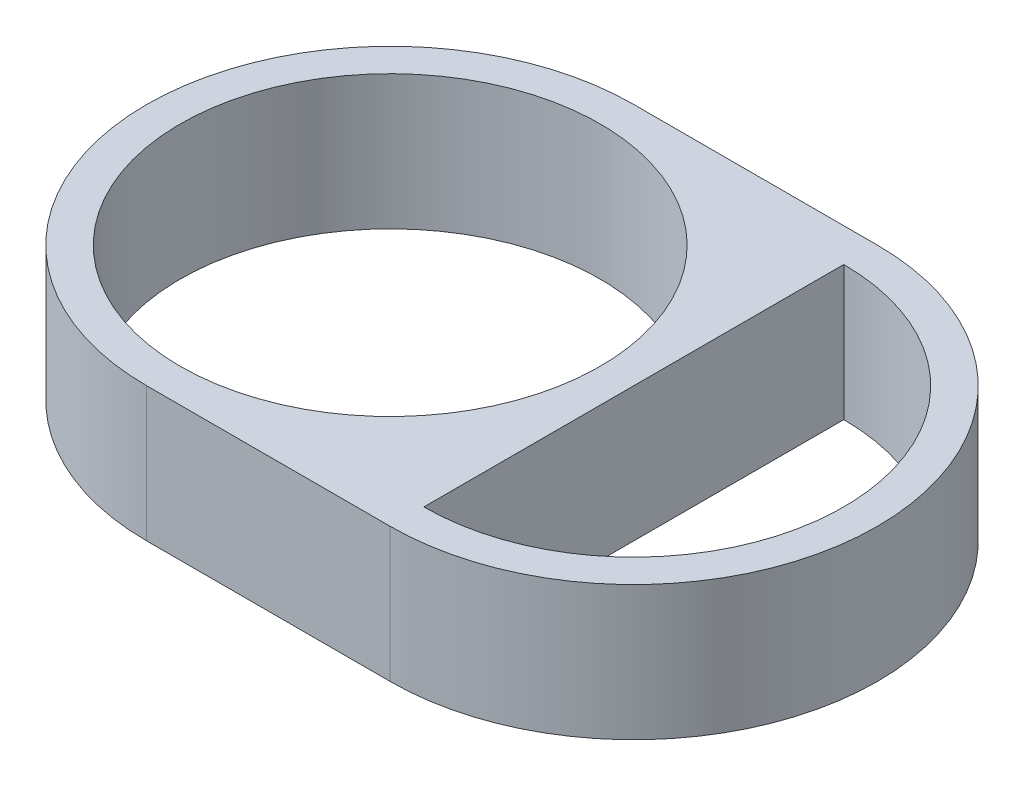
from build123d import *

# Parameters (mm, degrees)
SKETCH_1_R      = 12.5
EXTRUDE_1_DEPTH = 8
EXTRUDE_2_DEPTH = 8


with BuildPart() as part:
    # 草图1 → 凸台-拉伸1 (new body)
    with BuildSketch(Plane(origin=(0, 0, 0), x_dir=(1, 0, 0), z_dir=(0, 1, 0))):
        with BuildLine():
            ThreePointArc((0, 14.5), (-14.5, 0), (0, -14.5))
            Line((0, -14.5), (14.5, -14.5))
            Line((14.5, -14.5), (14.5, -12.5))
            Line((14.5, -12.5), (14.5, 12.5))
            Line((14.5, 12.5), (14.5, 14.5))
            Line((14.5, 14.5), (0, 14.5))
        make_face()
        Circle(SKETCH_1_R, mode=Mode.SUBTRACT)
    extrude(amount=EXTRUDE_1_DEPTH)

    # 草图1<3> → 凸台-拉伸2 (add)
    with BuildSketch(Plane(origin=(0, 0, 0), x_dir=(1, 0, 0), z_dir=(0, 1, 0))):
        with BuildLine():
            Line((14.5, -12.5), (14.5, -14.5))
            ThreePointArc((14.5, -14.5), (29, 0), (14.5, 14.5))
            Line((14.5, 14.5), (14.5, 12.5))
            ThreePointArc((14.5, 12.5), (27, 0), (14.5, -12.5))
        make_face()
    extrude(amount=EXTRUDE_2_DEPTH)


solid = part.part
